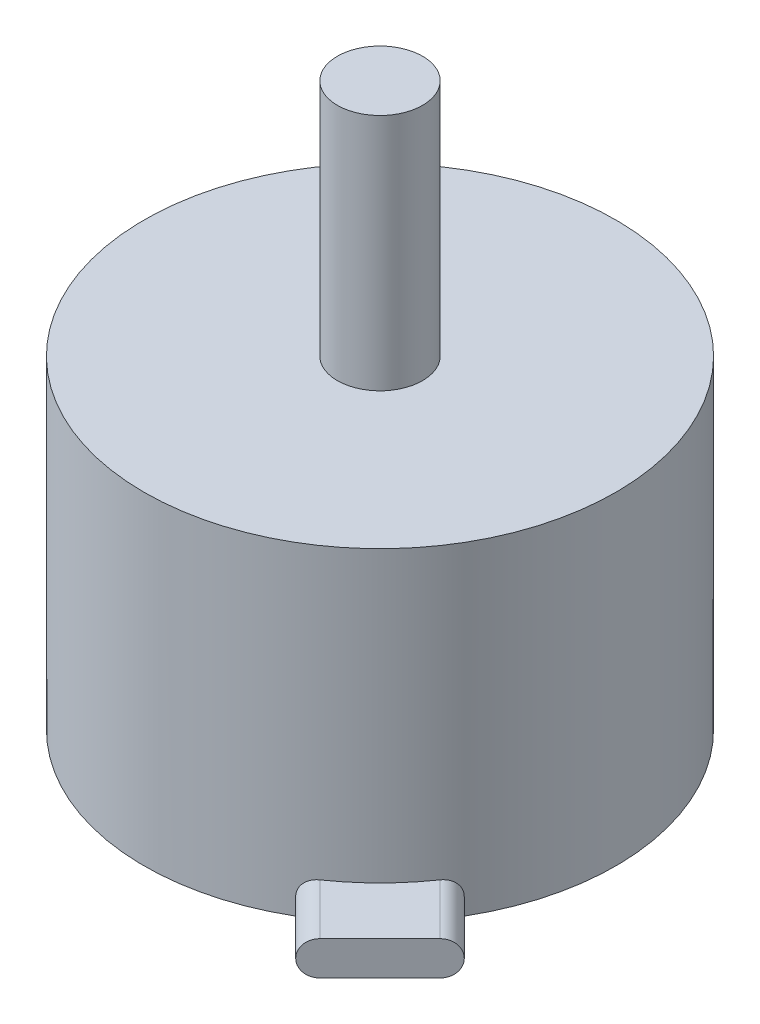
from build123d import *

# Parameters (mm, degrees)
SKETCH1_R                 = 13.85
BOSS_EXTRUDE1_DEPTH       = 19
SKETCH2_R                 = 2.5
BOSS_EXTRUDE2_DEPTH       = 14
M3X0_5_TAPPED_HOLE1_D     = 2.5
M3X0_5_TAPPED_HOLE1_DEPTH = 7.5
M3X0_5_TAPPED_HOLE1_TIP   = 0.751075774
BOSS_EXTRUDE3_START       = -0.449533
BOSS_EXTRUDE3_DEPTH       = 4.449533


with BuildPart() as part:
    # Sketch1 → Boss-Extrude1 (new body)
    with BuildSketch(Plane(origin=(0, 0, 0), x_dir=(1, 0, 0), z_dir=(0, 1, 0))):
        Circle(SKETCH1_R)
    extrude(amount=BOSS_EXTRUDE1_DEPTH)

    # Sketch2 → Boss-Extrude2 (add)
    with BuildSketch(Plane(origin=(0, 19, 0), x_dir=(1, 0, 0), z_dir=(0, 1, 0))):
        Circle(SKETCH2_R)
    extrude(amount=BOSS_EXTRUDE2_DEPTH)

    # M3x0.5 Tapped Hole1
    with Locations(Plane(origin=(0, 0, 0), x_dir=(-1, 0, 0), z_dir=(0, -1, 0))):
        with Locations((0, -8), (9.5, 0), (0, 8), (-9.5, 0)):
            Hole(M3X0_5_TAPPED_HOLE1_D / 2, depth=M3X0_5_TAPPED_HOLE1_DEPTH)
            with Locations((0, 0, -(M3X0_5_TAPPED_HOLE1_DEPTH + M3X0_5_TAPPED_HOLE1_TIP / 2))):  # 118° drill point
                Cone(0, M3X0_5_TAPPED_HOLE1_D / 2, M3X0_5_TAPPED_HOLE1_TIP, mode=Mode.SUBTRACT)

    # Sketch7 → Boss-Extrude3 (add)
    with BuildSketch(Plane(origin=(9.793428919, 0, 9.793428919), x_dir=(0.707106781, 0, -0.707106781), z_dir=(0.707106781, 0, 0.707106781)).offset(BOSS_EXTRUDE3_START)):
        with BuildLine():
            Line((-2.5, 2), (2.5, 2))
            ThreePointArc((2.5, 2), (3.5, 1), (2.5, 0))
            Line((2.5, 0), (-2.5, 0))
            ThreePointArc((-2.5, 0), (-3.5, 1), (-2.5, 2))
        make_face()
    extrude(amount=BOSS_EXTRUDE3_DEPTH)


solid = part.part
